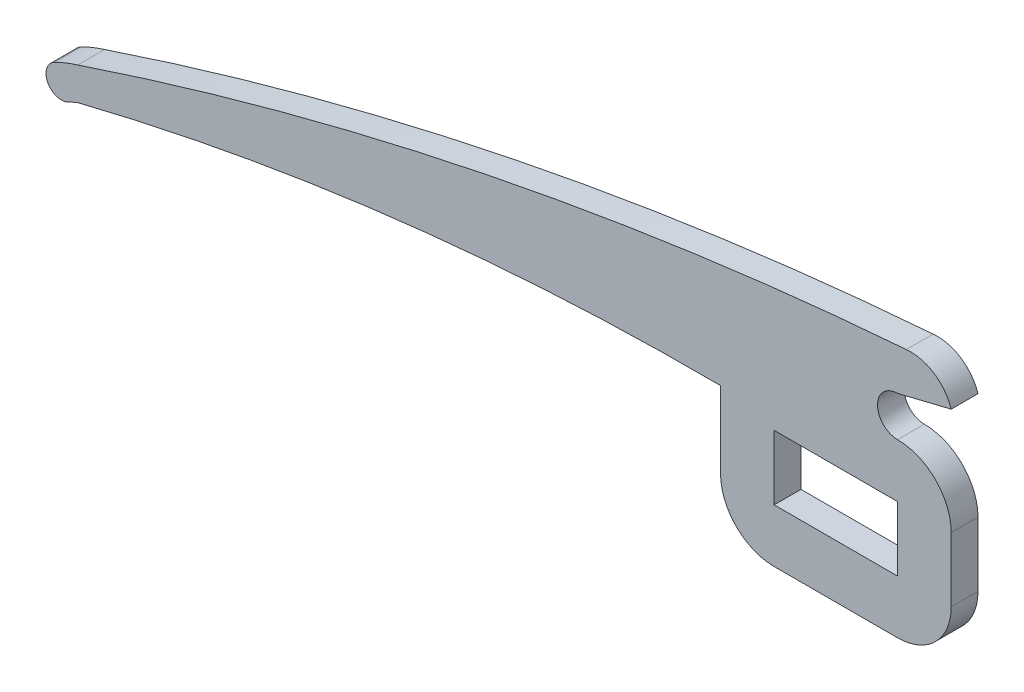
from build123d import *

# Parameters (mm, degrees)
SKETCH4_W           = 23.01079085
SKETCH4_H           = 12.035429775
BOSS_EXTRUDE1_DEPTH = 5


with BuildPart() as part:
    # Sketch4 → Boss-Extrude1 (new body)
    with BuildSketch(Plane.XY):
        with BuildLine():
            Line((-23.029498644, -9.969527596), (0.020059035, -9.969527596))
            ThreePointArc((0.020059035, -9.969527596), (7.083752781, -7.043649902), (10.009630666, 0.020043765))
            Line((10.009630666, 0.020043765), (10.009630666, 12.035429505))
            ThreePointArc((10.009630666, 12.035429505), (7.077737043, 19.110165135), (0.00232147, 22.0404175))
            ThreePointArc((0.00232147, 22.0404175), (-3.734235721, 25.776974691), (0.00232147, 29.513531883))
            Line((0.00232147, 29.513531883), (10.009630666, 31.965921786))
            ThreePointArc((10.009630666, 31.965921786), (6.784699168, 36.172527862), (1.631535857, 37.413747311))
            ThreePointArc((1.631535857, 37.413747311), (-76.612020645, 26.532654718), (-152.922807067, 6.10923224))
            ThreePointArc((-152.922807067, 6.10923224), (-155.131459045, 5.328115377), (-157.265351369, 4.361269649))
            ThreePointArc((-157.265351369, 4.361269649), (-158.533663589, 0.498259669), (-154.67065361, -0.770052551))
            ThreePointArc((-154.67065361, -0.770052551), (-153.805456008, -0.356328461), (-152.922807067, 0.018725346))
            ThreePointArc((-152.922807067, 0.018725346), (-93.417009782, 10.900895291), (-33.017751587, 14.261124841))
            Line((-33.017751587, 14.261124841), (-33.017751587, 12.035429775))
            Line((-33.017751587, 12.035429775), (-33.017751587, 0.018725346))
            ThreePointArc((-33.017751587, 0.018725346), (-30.092260032, -7.044036042), (-23.029498644, -9.969527596))
        make_face()
        with Locations((-11.505395425, 6.017714888)):
            Rectangle(SKETCH4_W, SKETCH4_H, mode=Mode.SUBTRACT)
    extrude(amount=BOSS_EXTRUDE1_DEPTH)


solid = part.part
